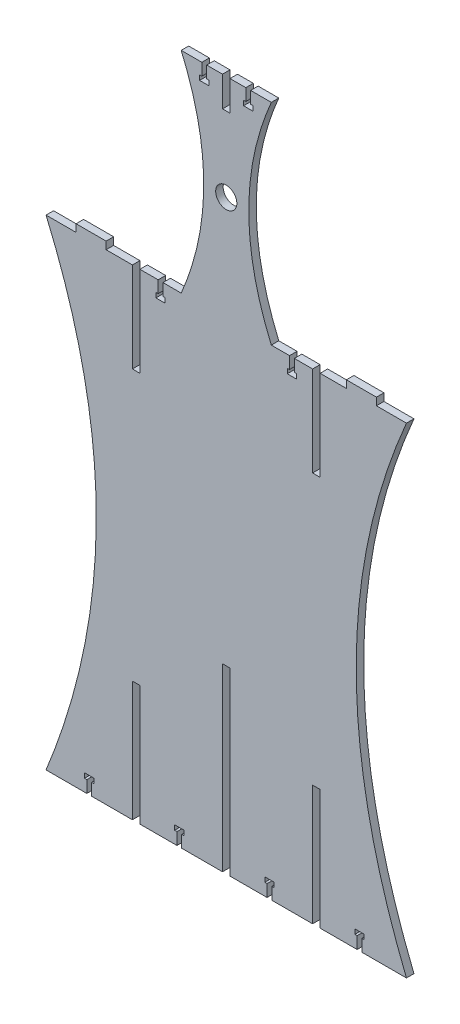
from build123d import *

# Parameters (mm, degrees)
SKETCH1_R           = 8.95
BOSS_EXTRUDE1_DEPTH = 6.35


with BuildPart() as part:
    # Sketch1 → Boss-Extrude1 (new body)
    with BuildSketch(Plane.XY):
        with BuildLine():
            Line((0, 0), (34.4805, 0))
            Line((34.4805, 0), (34.4805, 10.16))
            Line((34.4805, 10.16), (32.5755, 10.16))
            Line((32.5755, 10.16), (32.5755, 14.224))
            Line((32.5755, 14.224), (40.4495, 14.224))
            Line((40.4495, 14.224), (40.4495, 10.16))
            Line((40.4495, 10.16), (38.5445, 10.16))
            Line((38.5445, 10.16), (38.5445, 0))
            Line((38.5445, 0), (73.025, 0))
            Line((73.025, 0), (73.025, 101.6))
            Line((73.025, 101.6), (79.375, 101.6))
            Line((79.375, 101.6), (79.375, 0))
            Line((79.375, 0), (110.6805, 0))
            Line((110.6805, 0), (110.6805, 10.16))
            Line((110.6805, 10.16), (108.7755, 10.16))
            Line((108.7755, 10.16), (108.7755, 14.224))
            Line((108.7755, 14.224), (116.6495, 14.224))
            Line((116.6495, 14.224), (116.6495, 10.16))
            Line((116.6495, 10.16), (114.7445, 10.16))
            Line((114.7445, 10.16), (114.7445, 0))
            Line((114.7445, 0), (149.225, 0))
            Line((149.225, 0), (149.225, 152.4))
            Line((149.225, 152.4), (155.575, 152.4))
            Line((155.575, 152.4), (155.575, 0))
            Line((155.575, 0), (186.8805, 0))
            Line((186.8805, 0), (186.8805, 10.16))
            Line((186.8805, 10.16), (184.9755, 10.16))
            Line((184.9755, 10.16), (184.9755, 14.224))
            Line((184.9755, 14.224), (192.8495, 14.224))
            Line((192.8495, 14.224), (192.8495, 10.16))
            Line((192.8495, 10.16), (190.9445, 10.16))
            Line((190.9445, 10.16), (190.9445, 0))
            Line((190.9445, 0), (225.425, 0))
            Line((225.425, 0), (225.425, 101.6))
            Line((225.425, 101.6), (231.775, 101.6))
            Line((231.775, 101.6), (231.775, 0))
            Line((231.775, 0), (263.0805, 0))
            Line((263.0805, 0), (263.0805, 10.16))
            Line((263.0805, 10.16), (261.1755, 10.16))
            Line((261.1755, 10.16), (261.1755, 14.224))
            Line((261.1755, 14.224), (269.0495, 14.224))
            Line((269.0495, 14.224), (269.0495, 10.16))
            Line((269.0495, 10.16), (267.1445, 10.16))
            Line((267.1445, 10.16), (267.1445, 0))
            Line((267.1445, 0), (304.8, 0))
            add(Edge.make_bspline(
                [(304.8, 406.4), (219.863978117, 208.91880682), (304.8, 0)],
                knots=[0, 0, 0, 1, 1, 1], degree=2))
            Line((304.8, 406.4), (279.4, 406.4))
            Line((279.4, 406.4), (279.4, 412.75))
            Line((279.4, 412.75), (254, 412.75))
            Line((254, 412.75), (254, 406.4))
            Line((254, 406.4), (231.775, 406.4))
            Line((231.775, 406.4), (231.775, 330.2))
            Line((231.775, 330.2), (225.425, 330.2))
            Line((225.425, 330.2), (225.425, 406.4))
            Line((225.425, 406.4), (209.9945, 406.4))
            Line((209.9945, 406.4), (209.9945, 396.24))
            Line((209.9945, 396.24), (211.8995, 396.24))
            Line((211.8995, 396.24), (211.8995, 392.176))
            Line((211.8995, 392.176), (204.0255, 392.176))
            Line((204.0255, 392.176), (204.0255, 396.24))
            Line((204.0255, 396.24), (205.9305, 396.24))
            Line((205.9305, 396.24), (205.9305, 406.4))
            Line((205.9305, 406.4), (190.5, 406.4))
            add(Edge.make_bspline(
                [(190.5, 584.2), (152.371549644, 495.523357598), (190.5, 406.4)],
                knots=[0, 0, 0, 1, 1, 1], degree=2))
            Line((190.5, 584.2), (173.014669528, 584.2))
            Line((173.014669528, 584.2), (173.014669528, 574.04))
            Line((173.014669528, 574.04), (174.919669528, 574.04))
            Line((174.919669528, 574.04), (174.919669528, 569.976))
            Line((174.919669528, 569.976), (167.045669528, 569.976))
            Line((167.045669528, 569.976), (167.045669528, 574.04))
            Line((167.045669528, 574.04), (168.950669528, 574.04))
            Line((168.950669528, 574.04), (168.950669528, 584.2))
            Line((168.950669528, 584.2), (155.575, 584.2))
            Line((155.575, 584.2), (155.575, 558.8))
            Line((155.575, 558.8), (149.225, 558.8))
            Line((149.225, 558.8), (149.225, 584.2))
            Line((149.225, 584.2), (135.849330472, 584.2))
            Line((135.849330472, 584.2), (135.849330472, 574.04))
            Line((135.849330472, 574.04), (137.754330472, 574.04))
            Line((137.754330472, 574.04), (137.754330472, 569.976))
            Line((137.754330472, 569.976), (129.880330472, 569.976))
            Line((129.880330472, 569.976), (129.880330472, 574.04))
            Line((129.880330472, 574.04), (131.785330472, 574.04))
            Line((131.785330472, 574.04), (131.785330472, 584.2))
            Line((131.785330472, 584.2), (114.3, 584.2))
            add(Edge.make_bspline(
                [(114.3, 584.2), (152.428450356, 495.523357598), (114.3, 406.4)],
                knots=[0, 0, 0, 1, 1, 1], degree=2))
            Line((114.3, 406.4), (98.8695, 406.4))
            Line((98.8695, 406.4), (98.8695, 396.24))
            Line((98.8695, 396.24), (100.7745, 396.24))
            Line((100.7745, 396.24), (100.7745, 392.176))
            Line((100.7745, 392.176), (92.9005, 392.176))
            Line((92.9005, 392.176), (92.9005, 396.24))
            Line((92.9005, 396.24), (94.8055, 396.24))
            Line((94.8055, 396.24), (94.8055, 406.4))
            Line((94.8055, 406.4), (79.375, 406.4))
            Line((79.375, 406.4), (79.375, 330.2))
            Line((79.375, 330.2), (73.025, 330.2))
            Line((73.025, 330.2), (73.025, 406.4))
            Line((73.025, 406.4), (50.8, 406.4))
            Line((50.8, 406.4), (50.8, 412.75))
            Line((50.8, 412.75), (25.4, 412.75))
            Line((25.4, 412.75), (25.4, 406.4))
            Line((25.4, 406.4), (0, 406.4))
            add(Edge.make_bspline(
                [(0, 406.4), (84.936021883, 208.91880682), (0, 0)],
                knots=[0, 0, 0, 1, 1, 1], degree=2))
        make_face()
        with Locations((152.4, 495.55130888)):
            Circle(SKETCH1_R, mode=Mode.SUBTRACT)
    extrude(amount=BOSS_EXTRUDE1_DEPTH)


solid = part.part
